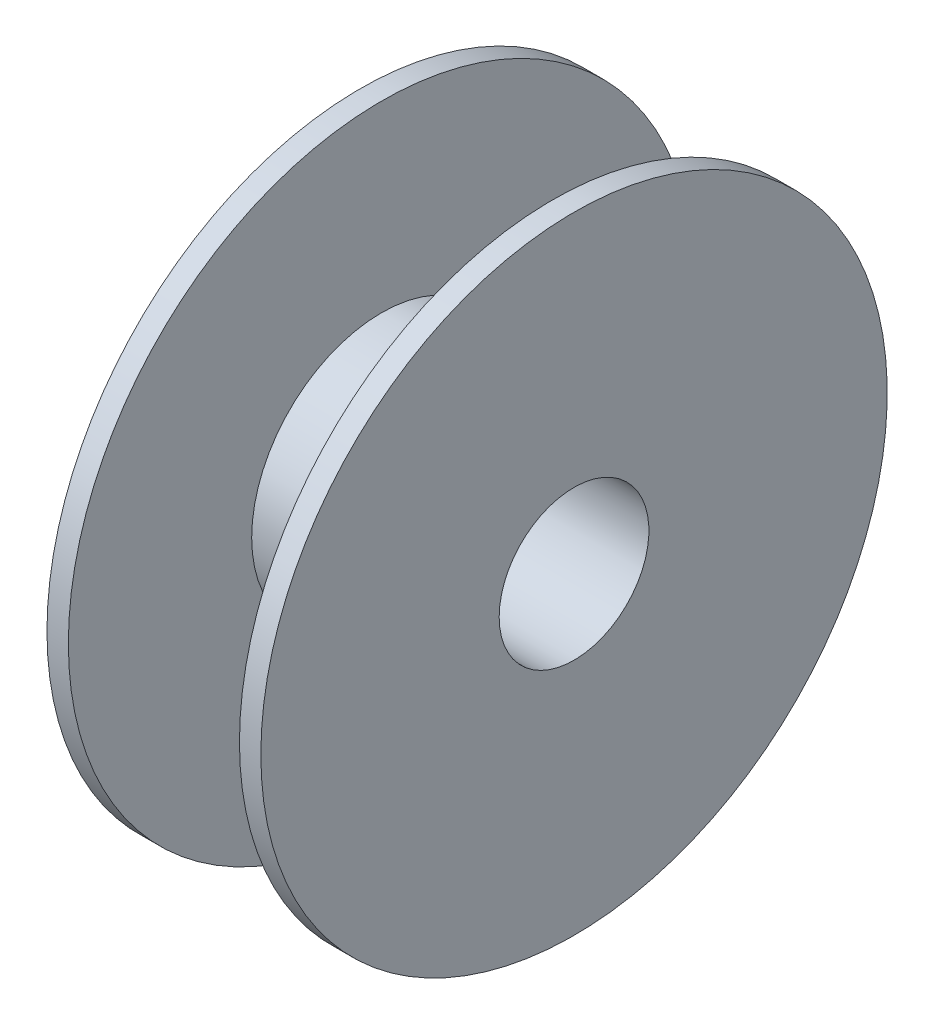
from build123d import *


with BuildPart() as part:
    # Esboço1 → Revolução1 (revolve)
    with BuildSketch(Plane(origin=(0, 0, 0), x_dir=(1, 0, 0), z_dir=(0, 1, 0))):
        Polygon((-35, 102.5), (-35, 24.5), (35, 24.5), (35, 102.5), (28, 102.5), (28, 42.5), (-28, 42.5), (-28, 102.5), align=None)
    revolve(axis=Axis((-72.731707317, 0, 0), (1, 0, 0)))


solid = part.part
